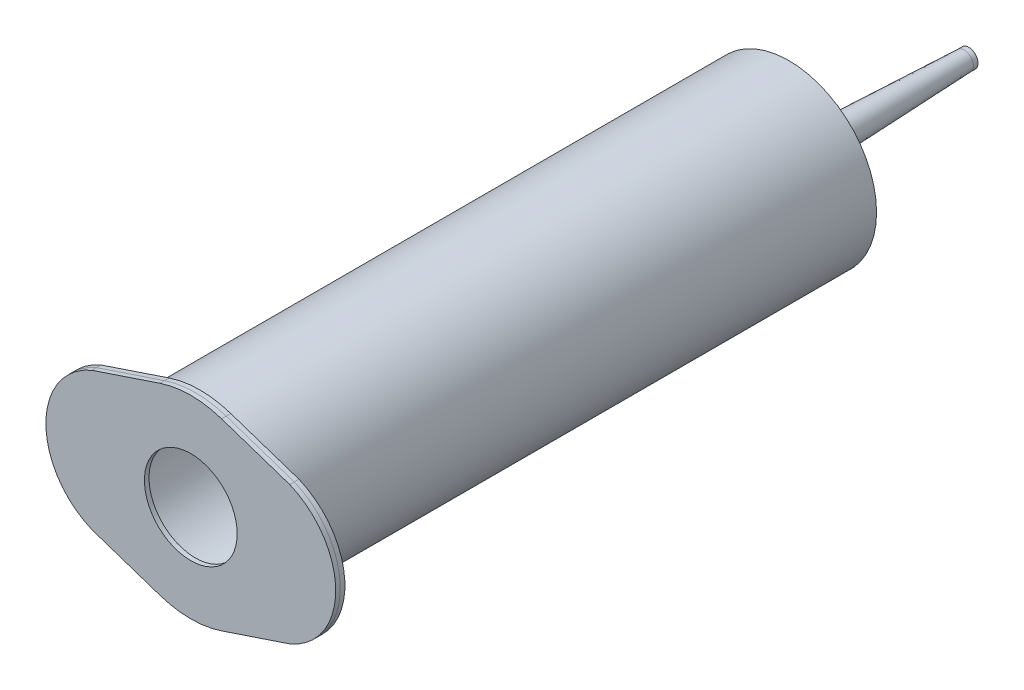
from build123d import *

# Parameters (mm, degrees)
SKETCH1_R           = 19.05
SKETCH1_R_2         = 15.08125
BOSS_EXTRUDE1_DEPTH = 127
BOSS_EXTRUDE2_START = -2
SKETCH1_2_R         = 19.05
BOSS_EXTRUDE2_DEPTH = 2
SKETCH2_R           = 2.5
CUT_EXTRUDE1_DEPTH  = 132.783174192
BOSS_EXTRUDE3_START = 1
SKETCH2_5_R         = 3.5
SKETCH2_5_R_2       = 2.5
BOSS_EXTRUDE3_DEPTH = 1
BOSS_EXTRUDE4_START = 38.1
SKETCH2_6_R         = 2
SKETCH2_6_R_2       = 1
BOSS_EXTRUDE4_DEPTH = 1
SKETCH4_R           = 19.05
BOSS_EXTRUDE5_DEPTH = 1
SKETCH4_3_R         = 10.08125
BOSS_EXTRUDE6_DEPTH = 1


with BuildPart() as part:
    # Sketch1 → Boss-Extrude1 (new body)
    with BuildSketch(Plane.XY):
        Circle(SKETCH1_R)
        Circle(SKETCH1_R_2, mode=Mode.SUBTRACT)
    extrude(amount=BOSS_EXTRUDE1_DEPTH)

    # Sketch1_2 → Boss-Extrude2 (add)
    with BuildSketch(Plane.XY.offset(BOSS_EXTRUDE2_START)):
        Circle(SKETCH1_2_R)
    extrude(amount=BOSS_EXTRUDE2_DEPTH)

    # Sketch2 → Cut-Extrude1 (cut, through all)
    with BuildSketch(Plane(origin=(0, 0, -2), x_dir=(-1, 0, 0), z_dir=(0, 0, -1))):
        Circle(SKETCH2_R)
    extrude(amount=-CUT_EXTRUDE1_DEPTH, mode=Mode.SUBTRACT)

    # Sketch2_5 → Boss-Extrude3 (add)
    with BuildSketch(Plane(origin=(0, 0, -2), x_dir=(-1, 0, 0), z_dir=(0, 0, -1)).offset(BOSS_EXTRUDE3_START)):
        Circle(SKETCH2_5_R)
        Circle(SKETCH2_5_R_2, mode=Mode.SUBTRACT)
    extrude(amount=-BOSS_EXTRUDE3_DEPTH)



with BuildPart() as body_2:
    # Sketch2_6 → Boss-Extrude4 (new body)
    with BuildSketch(Plane(origin=(0, 0, -2), x_dir=(-1, 0, 0), z_dir=(0, 0, -1)).offset(BOSS_EXTRUDE4_START)):
        Circle(SKETCH2_6_R)
        Circle(SKETCH2_6_R_2, mode=Mode.SUBTRACT)
    extrude(amount=BOSS_EXTRUDE4_DEPTH)


with BuildPart() as part_1:
    add(part.part)

    add(body_2.part)  # Revolve1 merges body 2
    # Sketch3 → Revolve1 (revolve)
    with BuildSketch(Plane(origin=(0, 0, 0), x_dir=(0, 0, -1), z_dir=(1, 0, 0))):
        Polygon((3, 3.5), (40.1, 2), (40.1, 1), (3, 2.5), align=None)
    revolve(axis=Axis((0, 0, 158.4), (0, 0, -1)))

    # Sketch4_3 → Boss-Extrude6 (add)
    with BuildSketch(Plane.XY.offset(127)):
        with BuildLine():
            Line((-6.683216494, 19.960889692), (-21.5, 15))
            ThreePointArc((-21.5, 15), (-31.5, 0), (-21.5, -15))
            Line((-21.5, -15), (-6.683216494, -19.960889692))
            ThreePointArc((-6.683216494, -19.960889692), (0, -21.05), (6.683216494, -19.960889692))
            Line((6.683216494, -19.960889692), (21.5, -15))
            ThreePointArc((21.5, -15), (31.5, 0), (21.5, 15))
            Line((21.5, 15), (6.683216494, 19.960889692))
            ThreePointArc((6.683216494, 19.960889692), (0, 21.05), (-6.683216494, 19.960889692))
        make_face()
        Circle(SKETCH4_3_R, mode=Mode.SUBTRACT)
    extrude(amount=BOSS_EXTRUDE6_DEPTH)


with BuildPart() as body_2_2:
    # Sketch4 → Boss-Extrude5 (new body)
    with BuildSketch(Plane.XY.offset(127)):
        with BuildLine():
            Line((-6.683216494, 19.960889692), (-21.5, 15))
            ThreePointArc((-21.5, 15), (-31.5, 0), (-21.5, -15))
            Line((-21.5, -15), (-6.683216494, -19.960889692))
            ThreePointArc((-6.683216494, -19.960889692), (0, -21.05), (6.683216494, -19.960889692))
            Line((6.683216494, -19.960889692), (21.5, -15))
            ThreePointArc((21.5, -15), (31.5, 0), (21.5, 15))
            Line((21.5, 15), (6.683216494, 19.960889692))
            ThreePointArc((6.683216494, 19.960889692), (0, 21.05), (-6.683216494, 19.960889692))
        make_face()
        Circle(SKETCH4_R, mode=Mode.SUBTRACT)
    extrude(amount=-BOSS_EXTRUDE5_DEPTH)


solid = Compound([part_1.part, body_2_2.part])
